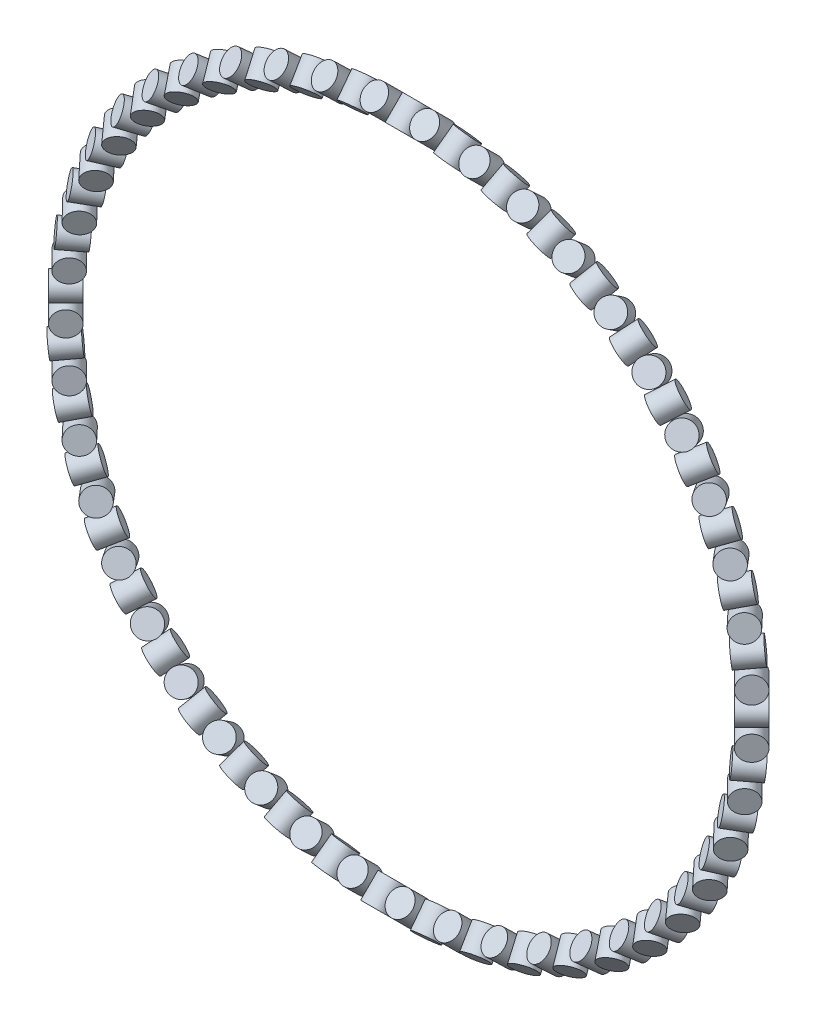
from build123d import *

# Parameters (mm, degrees)
SKETCH_1_R                 = 1
EXTRUDE_1_DEPTH            = 2
MOVE_BODY_1_ANGLE          = 45
MOVE_BODY_3_ANGLE          = 90
PATTERN_CIRCULAR_1_COUNT   = 44
PATTERN_CIRCULAR_1_2_COUNT = 44


with BuildPart() as part:
    # 草图1 → 凸台-拉伸1 (new body)
    with BuildSketch(Plane.XY):
        Circle(SKETCH_1_R)
    extrude(amount=EXTRUDE_1_DEPTH)


with BuildPart() as part_1:
    # Move Body 1: moved
    add(part.part.rotate(Axis((0, 0, 1), (1, 0, 0)), MOVE_BODY_1_ANGLE))


with BuildPart() as body_2:
    # Move Body 2: copy of part
    add(part_1.part.moved(Location((2, 0, 0))))


with BuildPart() as body_2_1:
    # Move Body 3: moved
    add(body_2.part.rotate(Axis((0, 0, 1), (1, 0, 0)), MOVE_BODY_3_ANGLE))


with BuildPart() as part_2:
    # Move Body 4: moved
    add(part_1.part.moved(Location((0, 28, 0))))

    # 阵列(圆周)1: part ×44 about axis
    pattern_circular_1_axis = Axis((0, 0, 0), (0, 0, 1))


with BuildPart() as body_2_2:
    # Move Body 4: moved
    add(body_2_1.part.moved(Location((0, 28, 0))))

    # Pattern Circular 1 2: body 2 ×44 about axis
    pattern_circular_1_2_axis = Axis((0, 0, 0), (0, 0, 1))


with BuildPart() as part_3:
    add(part_2.part)
    for i in range(1, PATTERN_CIRCULAR_1_COUNT):
        add(part_2.part.rotate(pattern_circular_1_axis, i * 360 / PATTERN_CIRCULAR_1_COUNT))


with BuildPart() as body_2_3:
    add(body_2_2.part)
    for i in range(1, PATTERN_CIRCULAR_1_2_COUNT):
        add(body_2_2.part.rotate(pattern_circular_1_2_axis, i * 360 / PATTERN_CIRCULAR_1_2_COUNT))


solid = Compound([part_3.part, body_2_3.part])
